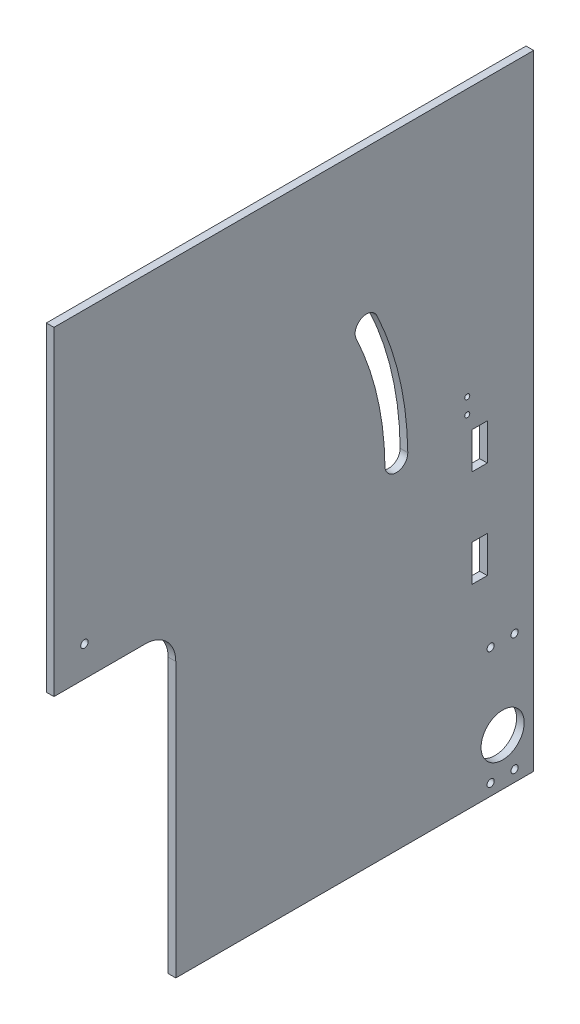
from build123d import *

# Parameters (mm, degrees)
SKETCH1_W           = 200.025
SKETCH1_H           = 260.35
BOSS_EXTRUDE1_DEPTH = 3.175
SKETCH8_R           = 1.55
SKETCH8_R_2         = 1.0499979
CUT_EXTRUDE7_DEPTH  = 4.175
SKETCH9_W           = 50.8
SKETCH9_H           = 127
CUT_EXTRUDE8_DEPTH  = 4.175
FILLET1_R           = 12.7
CUT_EXTRUDE9_DEPTH  = 4.175
SKETCH15_W          = 6.35
SKETCH15_H          = 15.24
CUT_EXTRUDE12_DEPTH = 4.175
SKETCH16_R          = 1.5
SKETCH16_R_2        = 9
CUT_EXTRUDE13_DEPTH = 4.175


with BuildPart() as part:
    # Sketch1 → Boss-Extrude1 (new body)
    with BuildSketch(Plane(origin=(0, 0, 0), x_dir=(0, 0, -1), z_dir=(1, 0, 0))):
        Rectangle(SKETCH1_W, SKETCH1_H)
    extrude(amount=BOSS_EXTRUDE1_DEPTH)

    # Sketch8 → Cut-Extrude7 (cut, through all)
    with BuildSketch(Plane.ZY):
        with Locations((87.3125, 9.525)):
            Circle(SKETCH8_R)
        with Locations((-72.3175, 18.9250066)):
            Circle(SKETCH8_R_2)
        with Locations((-72.3175, 12.4249942)):
            Circle(SKETCH8_R_2)
    extrude(amount=-CUT_EXTRUDE7_DEPTH, mode=Mode.SUBTRACT)

    # Sketch9 → Cut-Extrude8 (cut, through all)
    with BuildSketch(Plane.ZY):
        with Locations((74.6125, -66.675)):
            Rectangle(SKETCH9_W, SKETCH9_H)
    extrude(amount=-CUT_EXTRUDE8_DEPTH, mode=Mode.SUBTRACT)

    # Fillet1
    fillet1_edges = [part.edges().sort_by_distance(p)[0] for p in [
        (1.5875, -3.175, 49.2125),
    ]]
    fillet(fillet1_edges, radius=FILLET1_R)

    # Sketch10 → Cut-Extrude9 (cut, through all)
    with BuildSketch(Plane.ZY):
        with BuildLine():
            ThreePointArc((-34.631218673, 67.095364965), (-44.09213985, 39.8142402), (-47.528128749, 11.144346963))
            ThreePointArc((-47.528128749, 11.144346963), (-42.823162504, 6.325000001), (-38.003815542, 11.029966247))
            ThreePointArc((-38.003815542, 11.029966247), (-34.810523806, 37.674794334), (-26.017864022, 63.028948034))
            ThreePointArc((-26.017864022, 63.028948034), (-28.291332832, 69.36883393), (-34.631218673, 67.095364965))
        make_face()
    extrude(amount=-CUT_EXTRUDE9_DEPTH, mode=Mode.SUBTRACT)

    # Sketch15 → Cut-Extrude12 (cut, through all)
    with BuildSketch(Plane(origin=(3.175, 0, 0), x_dir=(0, 0, -1), z_dir=(1, 0, 0))):
        with Locations((77.4925, -1.5450058)):
            Rectangle(SKETCH15_W, SKETCH15_H)
        with Locations((77.4925, -42.1850058)):
            Rectangle(SKETCH15_W, SKETCH15_H)
    extrude(amount=-CUT_EXTRUDE12_DEPTH, mode=Mode.SUBTRACT)

    # Sketch16 → Cut-Extrude13 (cut, through all)
    with BuildSketch(Plane(origin=(3.175, 0, 0), x_dir=(0, 0, -1), z_dir=(1, 0, 0))):
        with Locations((82.075, -125.4125)):
            Circle(SKETCH16_R)
        with Locations((82.075, -76.4125)):
            Circle(SKETCH16_R)
        with Locations((92.075, -125.4125)):
            Circle(SKETCH16_R)
        with Locations((92.075, -76.4125)):
            Circle(SKETCH16_R)
        with Locations((87.075, -110.5624916)):
            Circle(SKETCH16_R_2)
    extrude(amount=-CUT_EXTRUDE13_DEPTH, mode=Mode.SUBTRACT)


solid = part.part
